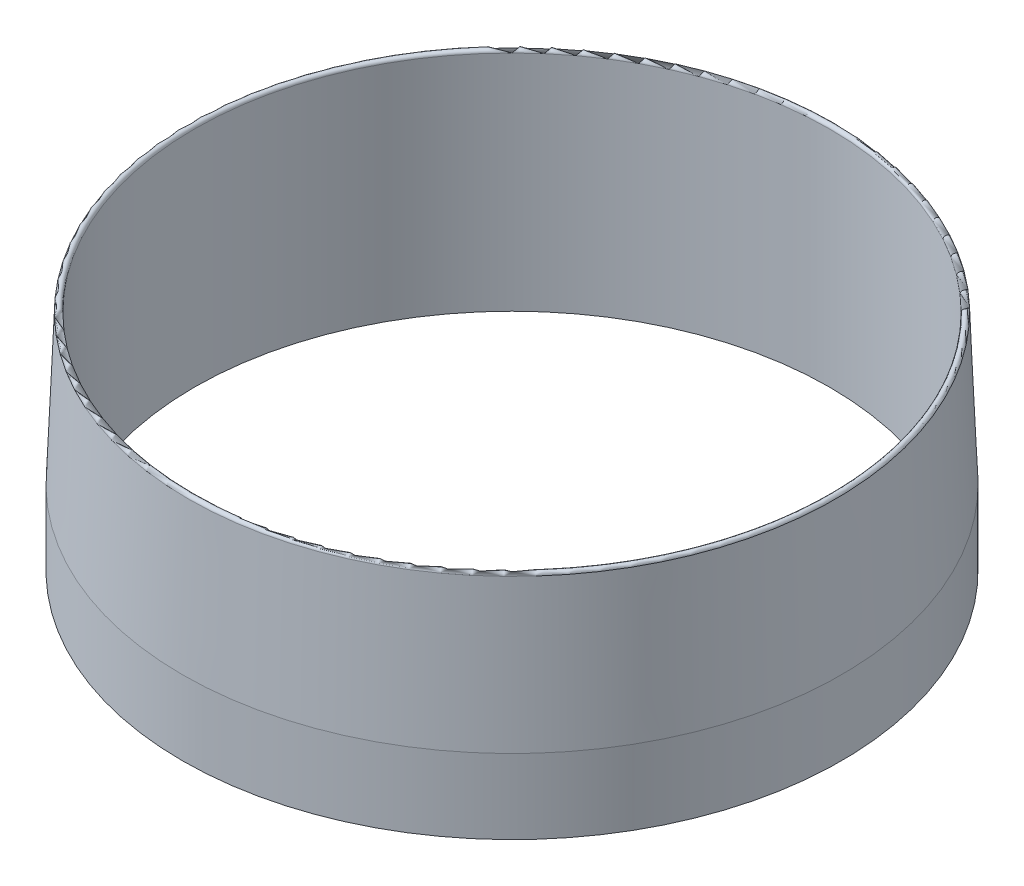
from build123d import *

# Parameters (mm, degrees)
FILLET1_R = 0.254


with BuildPart() as part:
    # Sketch1 → Revolve1 (revolve)
    with BuildSketch(Plane.XY):
        Polygon((27.051, 0), (28.067, 0), (28.067, 6.35), (27.051, 31.75), align=None)
    revolve(axis=Axis((0, -0.9525, 0), (0, 1, 0)))

    # Fillet1
    fillet1_edges = [part.edges().sort_by_distance(p)[0] for p in [
        (-27.051, 31.75, 0),
    ]]
    fillet(fillet1_edges, radius=FILLET1_R)


solid = part.part
